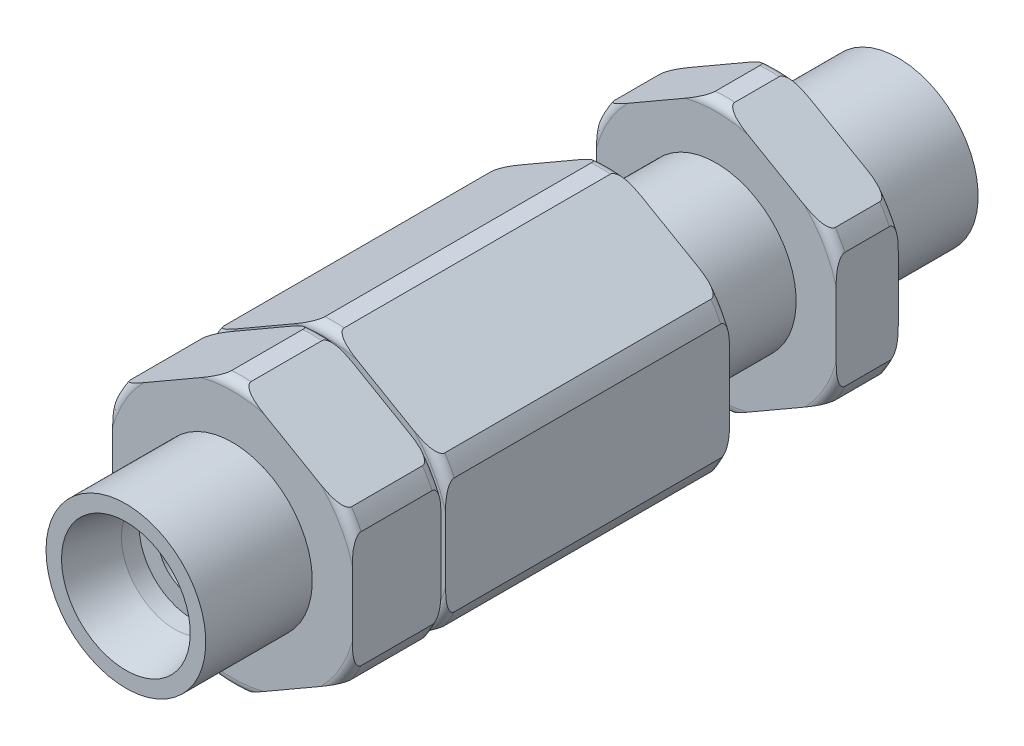
from build123d import *

# Parameters (mm, degrees)
EXTRUDE1_DEPTH = 87


with BuildPart() as part:
    # Sketch1 → Extrude1 (new body)
    with BuildSketch(Plane.XY):
        Polygon((13.5, -7.794228634), (13.5, 7.794228634), (0, 15.588457268), (-13.5, 7.794228634), (-13.5, -7.794228634), (0, -15.588457268), align=None)
    extrude(amount=EXTRUDE1_DEPTH)

    # Sketch2 → Cut-Revolve1 (revolve, cut)
    with BuildSketch(Plane(origin=(0, 0, 0), x_dir=(0, 0, -1), z_dir=(1, 0, 0))):
        with BuildLine():
            Line((-87, 15.588457268), (-87, 9))
            Line((-87, 9), (-75, 9))
            Line((-75, 9), (-75, 14))
            ThreePointArc((-75, 14), (-74.707106781, 14.707106781), (-74, 15))
            Line((-74, 15), (-66, 15))
            ThreePointArc((-66, 15), (-65.292893219, 14.707106781), (-65, 14))
            Line((-65, 14), (-65, 9))
            Line((-65, 9), (-64.5, 9))
            Line((-64.5, 9), (-64.5, 14))
            ThreePointArc((-64.5, 14), (-64.207106781, 14.707106781), (-63.5, 15))
            Line((-63.5, 15), (-33.5, 15))
            ThreePointArc((-33.5, 15), (-32.792893219, 14.707106781), (-32.5, 14))
            Line((-32.5, 14), (-32.5, 9))
            Line((-32.5, 9), (-20.5, 9))
            Line((-20.5, 9), (-20.5, 14))
            ThreePointArc((-20.5, 14), (-20.207106781, 14.707106781), (-19.5, 15))
            Line((-19.5, 15), (-14.5, 15))
            ThreePointArc((-14.5, 15), (-13.792893219, 14.707106781), (-13.5, 14))
            Line((-13.5, 14), (-13.5, 9))
            Line((-13.5, 9), (0, 9))
            Line((0, 9), (0, 15.588457268))
            Line((0, 15.588457268), (-87, 15.588457268))
        make_face()
    revolve(axis=Axis((0, 0, 0), (0, 0, 1)), mode=Mode.SUBTRACT)

    # Sketch3 → Cut-Revolve2 (revolve, cut)
    with BuildSketch(Plane(origin=(0, 0, 0), x_dir=(0, 0, -1), z_dir=(1, 0, 0))):
        Polygon((0, 7.25), (-5.5, 6), (-7.5, 6), (-7.5, 3.9), (-79.5, 3.9), (-79.5, 6), (-81.5, 6), (-87, 7.25), (-87, 0), (0, 0), align=None)
    revolve(axis=Axis((0, 0, 0), (0, 0, 1)), mode=Mode.SUBTRACT)


solid = part.part
